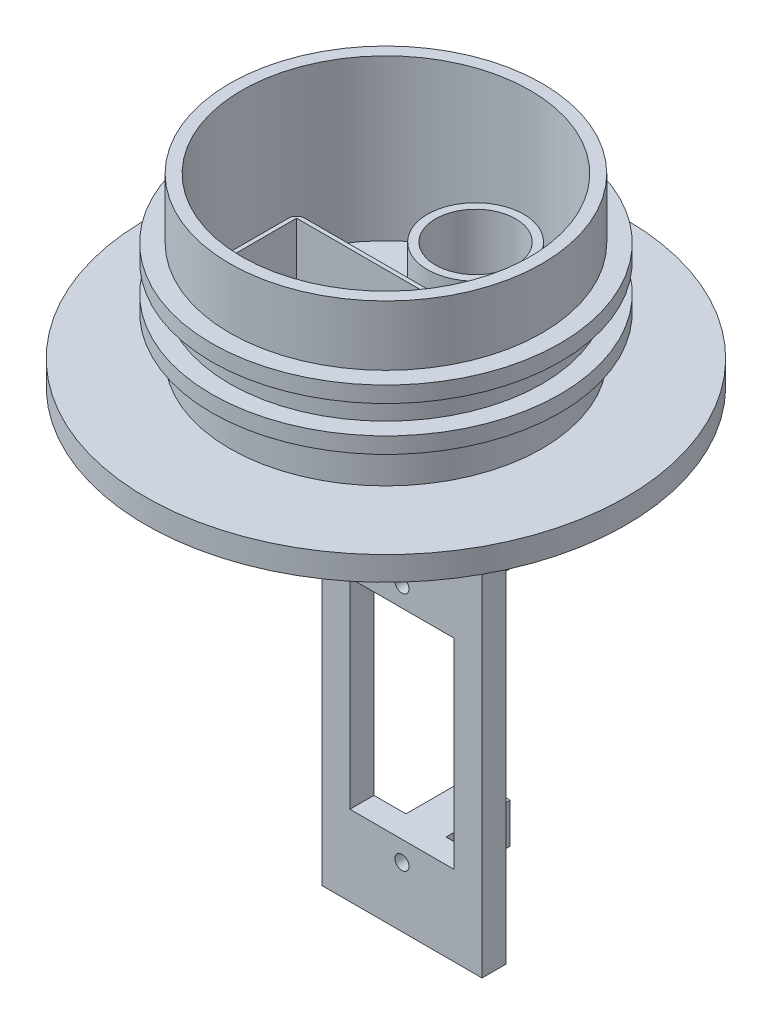
from build123d import *

# Parameters (mm, degrees)
SKETCH_1_R               = 19.5
SKETCH_1_R_2             = 18
EXTRUDE_1_DEPTH          = 20
SKETCH_3_R               = 30
EXTRUDE_2_DEPTH          = 3
SKETCH_10_R              = 6
SKETCH_10_R_2            = 5
EXTRUDE_6_DEPTH          = 10
SKETCH_11_R              = 5.007506695
CUT_EXTRUDE_4_DEPTH      = 19
CUT_EXTRUDE_4_DEPTH_BACK = 10
SKETCH_15_W              = 20
SKETCH_15_H              = 60
SKETCH_15_W_2            = 13
SKETCH_15_H_2            = 25
EXTRUDE_7_DEPTH          = 1
EXTRUDE_7_DEPTH_BACK     = 2
SKETCH_16_W              = 5
SKETCH_16_H              = 5
EXTRUDE_8_DEPTH          = 10
SKETCH_18_R              = 0.875
CUT_EXTRUDE_5_DEPTH      = 10
CUT_EXTRUDE_5_DEPTH_BACK = 39
SKETCH_12_W              = 21.5
SKETCH_12_H              = 13
CUT_EXTRUDE_6_DEPTH      = 21.5
SKETCH_19_W              = 22.5
SKETCH_19_H              = 14
SKETCH_19_W_2            = 21.5
SKETCH_19_H_2            = 13
EXTRUDE_9_DEPTH          = 10
FILLET_2_R               = 1
FILLET_3_R               = 1
FILLET_4_R               = 1
FILLET_5_R               = 1
SKETCH_25_R              = 21.75
SKETCH_25_R_2            = 19.5
EXTRUDE_12_DEPTH         = 2
SKETCH_26_R              = 21.75
SKETCH_26_R_2            = 19.5
EXTRUDE_13_DEPTH         = 2


with BuildPart() as part:
    # 草圖1 → 填料-伸長1 (new body)
    with BuildSketch(Plane(origin=(0, 0, 0), x_dir=(1, 0, 0), z_dir=(0, 1, 0))):
        Circle(SKETCH_1_R)
        Circle(SKETCH_1_R_2, mode=Mode.SUBTRACT)
    extrude(amount=EXTRUDE_1_DEPTH)

    # 草圖3 → 填料-伸長2 (add)
    with BuildSketch(Plane.XZ):
        Circle(SKETCH_3_R)
    extrude(amount=EXTRUDE_2_DEPTH)

    # 草圖10 → 填料-伸長6 (add)
    with BuildSketch(Plane(origin=(0, -3, 0), x_dir=(-1, 0, 0), z_dir=(0, -1, 0))):
        with Locations((0, 11.196036894)):
            Circle(SKETCH_10_R)
        with Locations((0, 11.196036894)):
            Circle(SKETCH_10_R_2, mode=Mode.SUBTRACT)
    extrude(amount=-EXTRUDE_6_DEPTH)

    # 草圖11 → 除料-伸長4 (cut, two sides)
    with BuildSketch(Plane(origin=(0, -3, 0), x_dir=(-1, 0, 0), z_dir=(0, -1, 0))) as cut_extrude_4_sk:
        with Locations((0, 11.196036894)):
            Circle(SKETCH_11_R)
    extrude(amount=CUT_EXTRUDE_4_DEPTH, mode=Mode.SUBTRACT)
    extrude(cut_extrude_4_sk.sketch, amount=-CUT_EXTRUDE_4_DEPTH_BACK, mode=Mode.SUBTRACT)

    # 草圖15 → 填料-伸長7 (add, two sides)
    with BuildSketch(Plane.XY.offset(-3)) as extrude_7_sk:
        with Locations((0, -33)):
            Rectangle(SKETCH_15_W, SKETCH_15_H)
        with Locations((0, -40.5)):
            Rectangle(SKETCH_15_W_2, SKETCH_15_H_2, mode=Mode.SUBTRACT)
    extrude(amount=EXTRUDE_7_DEPTH)
    extrude(extrude_7_sk.sketch, amount=-EXTRUDE_7_DEPTH_BACK)

    # 草圖16 → 填料-伸長8 (add)
    with BuildSketch(Plane.XY.offset(-3)):
        with Locations((0, -25.5)):
            Rectangle(SKETCH_16_W, SKETCH_16_H)
        with Locations((0, -55.5)):
            Rectangle(SKETCH_16_W, SKETCH_16_H)
    extrude(amount=-EXTRUDE_8_DEPTH)

    # 草圖18 → 除料-伸長5 (cut, two sides)
    with BuildSketch(Plane.XY) as cut_extrude_5_sk:
        with Locations((0, -55.5)):
            Circle(SKETCH_18_R)
        with Locations((0, -25.5)):
            Circle(SKETCH_18_R)
    extrude(amount=CUT_EXTRUDE_5_DEPTH, mode=Mode.SUBTRACT)
    extrude(cut_extrude_5_sk.sketch, amount=-CUT_EXTRUDE_5_DEPTH_BACK, mode=Mode.SUBTRACT)

    # 草圖12 → 除料-伸長6 (cut)
    with BuildSketch(Plane.XZ.offset(3)):
        with Locations((0, 6.907998134)):
            Rectangle(SKETCH_12_W, SKETCH_12_H)
    extrude(amount=-CUT_EXTRUDE_6_DEPTH, mode=Mode.SUBTRACT)

    # 草圖19 → 填料-伸長9 (add)
    with BuildSketch(Plane(origin=(0, 0, 0), x_dir=(1, 0, 0), z_dir=(0, 1, 0))):
        with Locations((0, -6.907998134)):
            Rectangle(SKETCH_19_W, SKETCH_19_H)
        with Locations((0, -6.907998134)):
            Rectangle(SKETCH_19_W_2, SKETCH_19_H_2, mode=Mode.SUBTRACT)
    extrude(amount=EXTRUDE_9_DEPTH)

    # 圓角2
    fillet_2_edges = [part.edges().sort_by_distance(p)[0] for p in [
        (-11.25, 5, -0.092001866),
    ]]
    fillet(fillet_2_edges, radius=FILLET_2_R)

    # 圓角3
    fillet_3_edges = [part.edges().sort_by_distance(p)[0] for p in [
        (11.25, 5, -0.092001866),
    ]]
    fillet(fillet_3_edges, radius=FILLET_3_R)

    # 圓角4
    fillet_4_edges = [part.edges().sort_by_distance(p)[0] for p in [
        (11.25, 5, 13.907998134),
    ]]
    fillet(fillet_4_edges, radius=FILLET_4_R)

    # 圓角5
    fillet_5_edges = [part.edges().sort_by_distance(p)[0] for p in [
        (-11.25, 5, 13.907998134),
    ]]
    fillet(fillet_5_edges, radius=FILLET_5_R)

    # 草圖25 → 填料-伸長12 (add)
    with BuildSketch(Plane(origin=(0, 7, 0), x_dir=(-1, 0, 0), z_dir=(0, -1, 0))):
        Circle(SKETCH_25_R)
        Circle(SKETCH_25_R_2, mode=Mode.SUBTRACT)
    extrude(amount=EXTRUDE_12_DEPTH)

    # 草圖26 → 填料-伸長13 (add)
    with BuildSketch(Plane(origin=(0, 10.5, 0), x_dir=(-1, 0, 0), z_dir=(0, -1, 0))):
        Circle(SKETCH_26_R)
        Circle(SKETCH_26_R_2, mode=Mode.SUBTRACT)
    extrude(amount=-EXTRUDE_13_DEPTH)


solid = part.part
